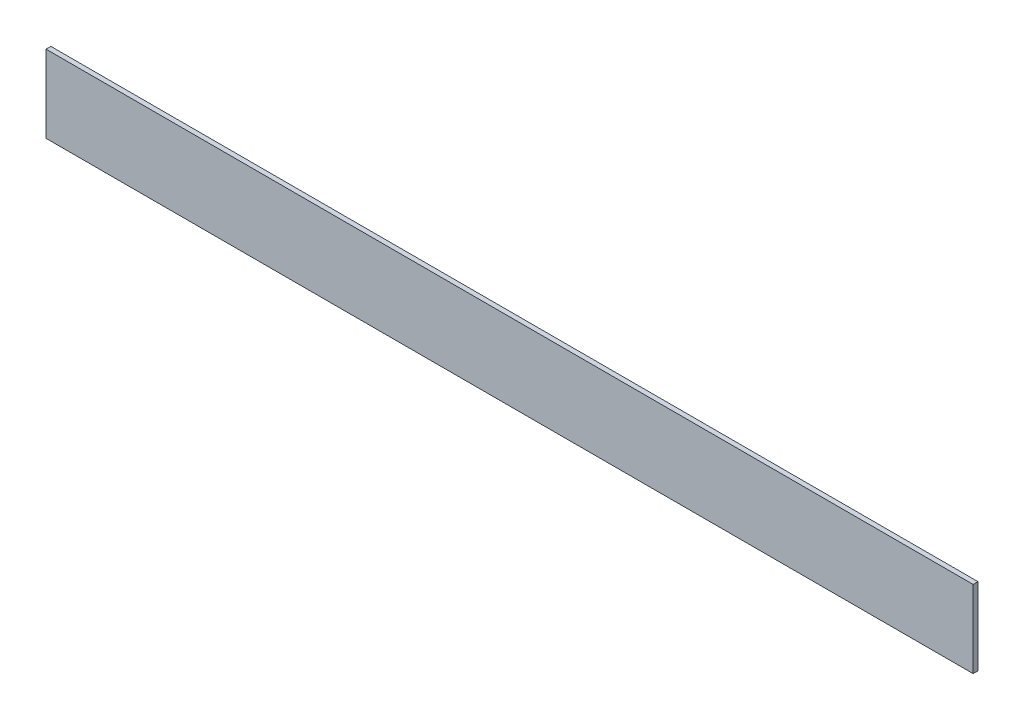
from build123d import *

# Parameters (mm, degrees)
SKETCH1_W           = 609.6
SKETCH1_H           = 50.8
BOSS_EXTRUDE1_DEPTH = 3.175


with BuildPart() as part:
    # Sketch1 → Boss-Extrude1 (new body)
    with BuildSketch(Plane.XY):
        Rectangle(SKETCH1_W, SKETCH1_H)
    extrude(amount=BOSS_EXTRUDE1_DEPTH)


solid = part.part
